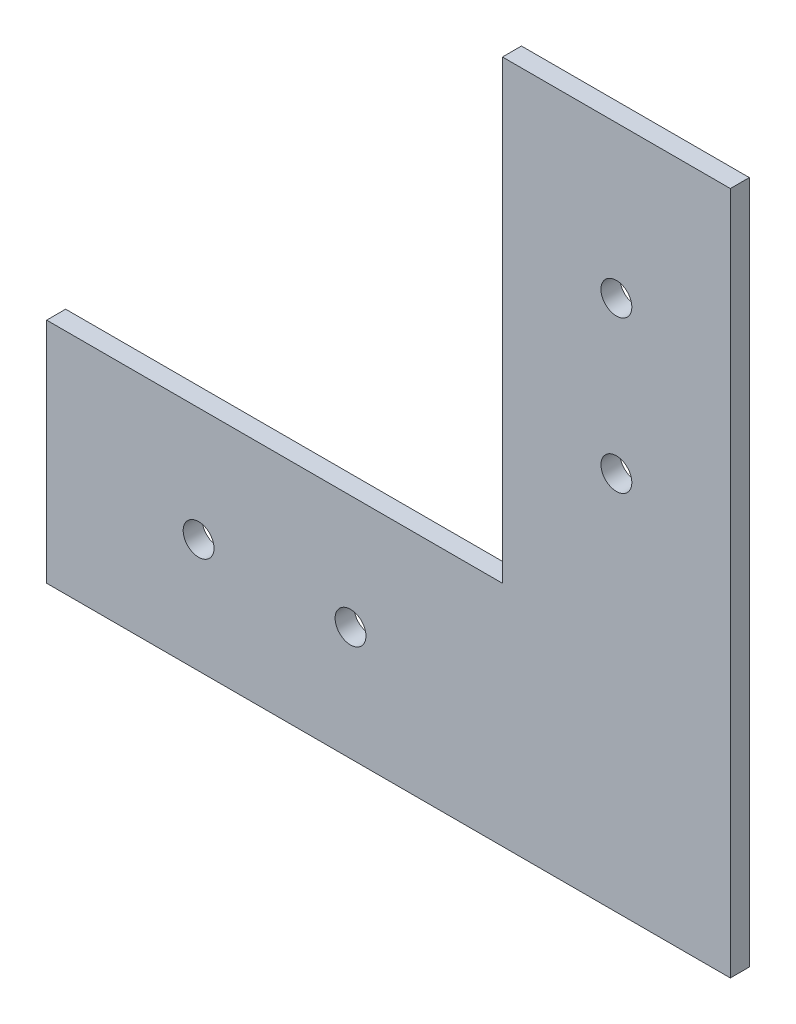
from build123d import *

# Parameters (mm, degrees)
BOSS_EXTRUDE1_DEPTH = 3.175
SKETCH2_R           = 2.5796875
CUT_EXTRUDE1_DEPTH  = 3.175


with BuildPart() as part:
    # Sketch1 → Boss-Extrude1 (new body)
    with BuildSketch(Plane.XY):
        Polygon((44.236797843, 51.486486486), (82.336797843, 51.486486486), (82.336797843, -62.813513514), (-31.963202157, -62.813513514), (-31.963202157, -24.713513514), (44.236797843, -24.713513514), align=None)
    extrude(amount=BOSS_EXTRUDE1_DEPTH)

    # Sketch2 → Cut-Extrude1 (cut)
    with BuildSketch(Plane.XY.offset(3.175)):
        with Locations((63.286797843, 26.086486486)):
            Circle(SKETCH2_R)
        with Locations((63.286797843, 0.686486486)):
            Circle(SKETCH2_R)
        with Locations((-6.563202157, -43.763513514)):
            Circle(SKETCH2_R)
        with Locations((18.836797843, -43.763513514)):
            Circle(SKETCH2_R)
    extrude(amount=-CUT_EXTRUDE1_DEPTH, mode=Mode.SUBTRACT)


solid = part.part
